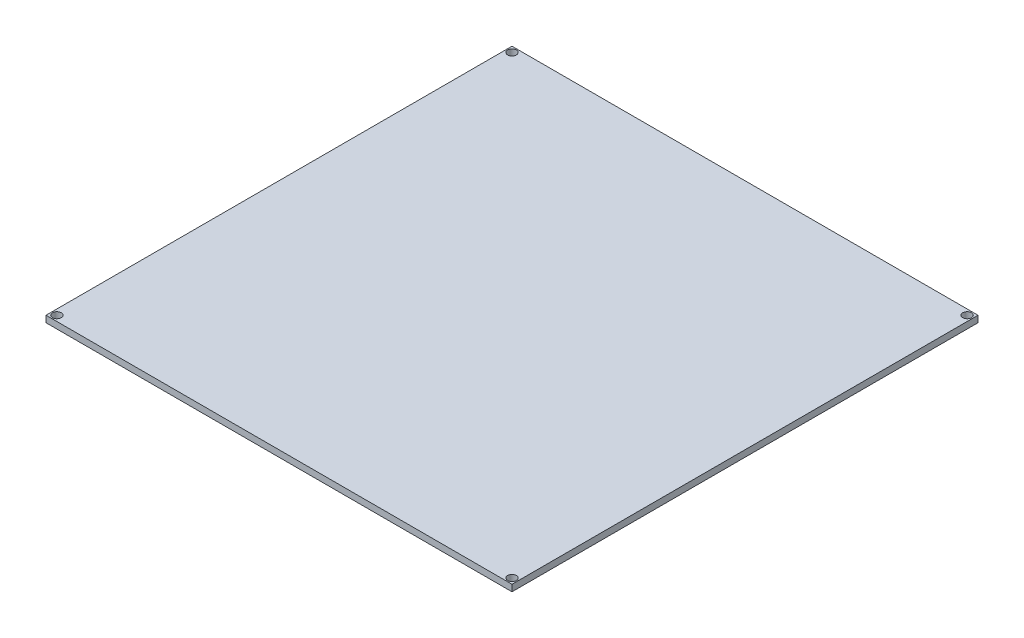
from build123d import *

# Parameters (mm, degrees)
SKETCH1_W           = 214
SKETCH1_H           = 214
SKETCH1_R           = 2
BOSS_EXTRUDE1_DEPTH = 3


with BuildPart() as part:
    # Sketch1 → Boss-Extrude1 (new body)
    with BuildSketch(Plane(origin=(0, 0, 0), x_dir=(1, 0, 0), z_dir=(0, 1, 0))):
        Rectangle(SKETCH1_W, SKETCH1_H)
        with Locations((-104.5, 104.5)):
            Circle(SKETCH1_R, mode=Mode.SUBTRACT)
        with Locations((104.5, 104.5)):
            Circle(SKETCH1_R, mode=Mode.SUBTRACT)
        with Locations((104.5, -104.5)):
            Circle(SKETCH1_R, mode=Mode.SUBTRACT)
        with Locations((-104.5, -104.5)):
            Circle(SKETCH1_R, mode=Mode.SUBTRACT)
    extrude(amount=BOSS_EXTRUDE1_DEPTH)


solid = part.part
